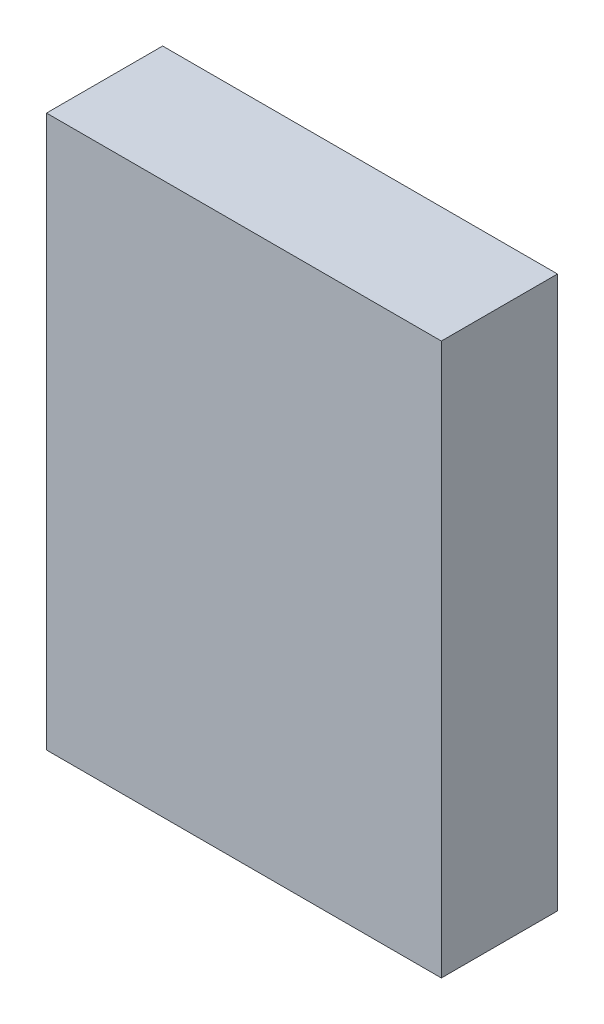
from build123d import *

# Parameters (mm, degrees)
SKETCH1_W           = 68
SKETCH1_H           = 20
BOSS_EXTRUDE1_DEPTH = 47.5


with BuildPart() as part:
    # Sketch1 → Boss-Extrude1 (new body, symmetric)
    with BuildSketch(Plane(origin=(0, 0, 0), x_dir=(1, 0, 0), z_dir=(0, 1, 0))):
        Rectangle(SKETCH1_W, SKETCH1_H)
    extrude(amount=BOSS_EXTRUDE1_DEPTH, both=True)


solid = part.part
